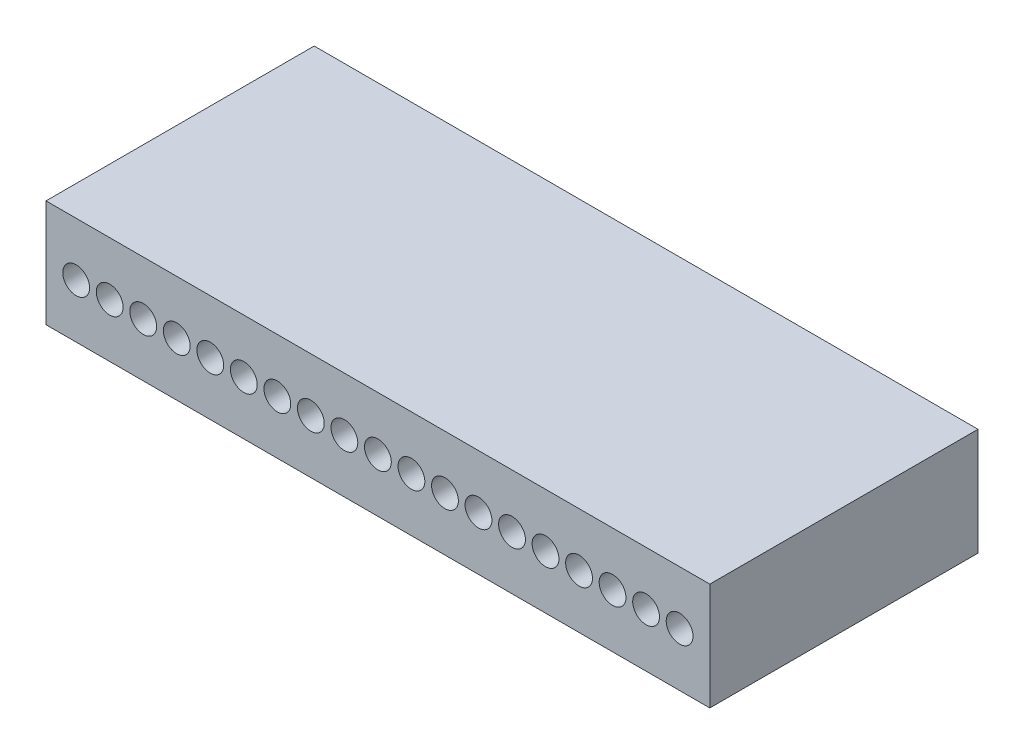
from build123d import *

# Parameters (mm, degrees)
SKETCH2_W           = 24.75
SKETCH2_H           = 4
BOSS_EXTRUDE1_DEPTH = 10
SKETCH3_R           = 0.5
CUT_EXTRUDE1_DEPTH  = 5


with BuildPart() as part:
    # Sketch2 → Boss-Extrude1 (new body)
    with BuildSketch(Plane.XY):
        with Locations((12.375, 2)):
            Rectangle(SKETCH2_W, SKETCH2_H)
    extrude(amount=BOSS_EXTRUDE1_DEPTH)

    # Sketch3 → Cut-Extrude1 (cut)
    with BuildSketch(Plane.XY.offset(10)):
        with Locations((1.125, 2)):
            Circle(SKETCH3_R)
        with Locations((2.375, 2)):
            Circle(SKETCH3_R)
        with Locations((3.625, 2)):
            Circle(SKETCH3_R)
        with Locations((4.875, 2)):
            Circle(SKETCH3_R)
        with Locations((6.125, 2)):
            Circle(SKETCH3_R)
        with Locations((7.375, 2)):
            Circle(SKETCH3_R)
        with Locations((8.625, 2)):
            Circle(SKETCH3_R)
        with Locations((9.875, 2)):
            Circle(SKETCH3_R)
        with Locations((11.125, 2)):
            Circle(SKETCH3_R)
        with Locations((12.375, 2)):
            Circle(SKETCH3_R)
        with Locations((13.625, 2)):
            Circle(SKETCH3_R)
        with Locations((14.875, 2)):
            Circle(SKETCH3_R)
        with Locations((16.125, 2)):
            Circle(SKETCH3_R)
        with Locations((17.375, 2)):
            Circle(SKETCH3_R)
        with Locations((18.625, 2)):
            Circle(SKETCH3_R)
        with Locations((19.875, 2)):
            Circle(SKETCH3_R)
        with Locations((21.125, 2)):
            Circle(SKETCH3_R)
        with Locations((22.375, 2)):
            Circle(SKETCH3_R)
        with Locations((23.625, 2)):
            Circle(SKETCH3_R)
    extrude(amount=-CUT_EXTRUDE1_DEPTH, mode=Mode.SUBTRACT)


solid = part.part
